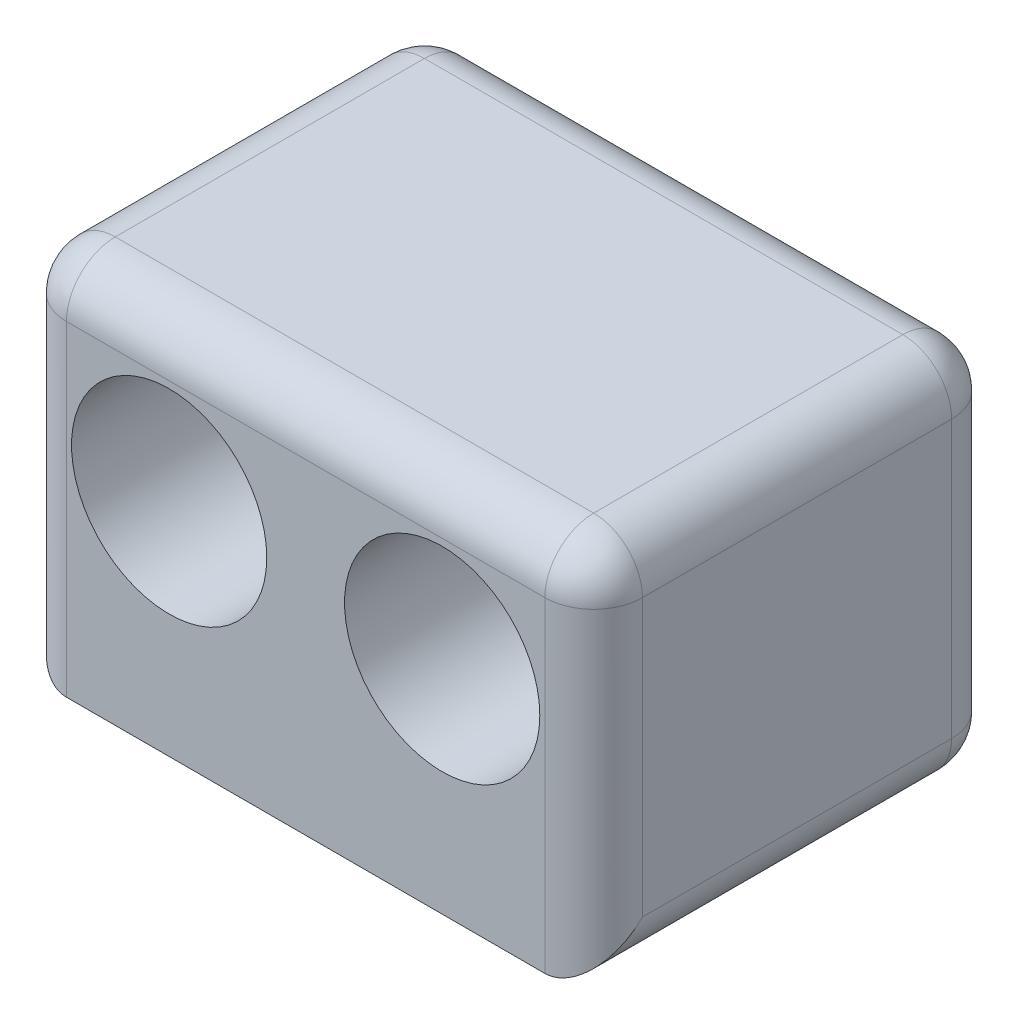
from build123d import *

# Parameters (mm, degrees)
ESBO_O1_W                = 17.7
ESBO_O1_H                = 11.5
RESSALTO_EXTRUS_O1_DEPTH = 12.5
ESBO_O2_R                = 3
CORTE_EXTRUS_O1_DEPTH    = 10
FILETE1_R                = 1.5


with BuildPart() as part:
    # Esboço1 → Ressalto-extrusão1 (new body)
    with BuildSketch(Plane.XY):
        Rectangle(ESBO_O1_W, ESBO_O1_H)
    extrude(amount=RESSALTO_EXTRUS_O1_DEPTH)

    # Esboço2 → Corte-extrusão1 (cut)
    with BuildSketch(Plane.XY.offset(12.5)):
        with Locations((4.195, 1.04)):
            Circle(ESBO_O2_R)
        with Locations((-4.195, 1.04)):
            Circle(ESBO_O2_R)
    extrude(amount=-CORTE_EXTRUS_O1_DEPTH, mode=Mode.SUBTRACT)

    # Filete1
    filete1_edges = [part.edges().sort_by_distance(p)[0] for p in [
        (-8.85, 0, 12.5),
        (8.85, 0, 12.5),
        (0, -5.75, 0),
        (-8.85, 0, 0),
        (0, 5.75, 0),
        (8.85, 0, 0),
        (8.85, -5.75, 6.25),
        (-8.85, -5.75, 6.25),
        (-8.85, 5.75, 6.25),
        (8.85, 5.75, 6.25),
        (0, 5.75, 12.5),
    ]]
    fillet(filete1_edges, radius=FILETE1_R)


solid = part.part
